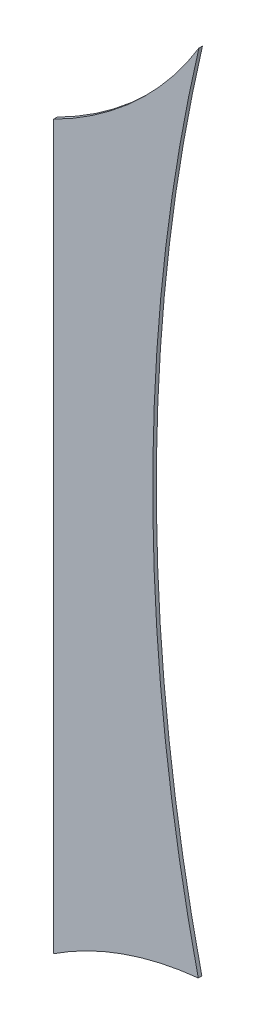
from build123d import *

# Parameters (mm, degrees)
SALIENTE_EXTRUIR1_DEPTH = 0.1


with BuildPart() as part:
    # Model → Saliente-Extruir1 (new body)
    with BuildSketch(Plane.XY):
        with BuildLine():
            Line((53.128798906, 12.541258878), (53.128798906, -7.661823012))
            ThreePointArc((53.128798906, -7.661823012), (55.064943579, -6.69975803), (57.174643265, -6.22711392))
            ThreePointArc((57.174643265, -6.22711392), (55.903300558, 5.035143254), (57.192993112, 16.295313858))
            ThreePointArc((57.192993112, 16.295313858), (55.425426316, 14.131902033), (53.128798906, 12.541258878))
        make_face()
    extrude(amount=SALIENTE_EXTRUIR1_DEPTH)


solid = part.part
